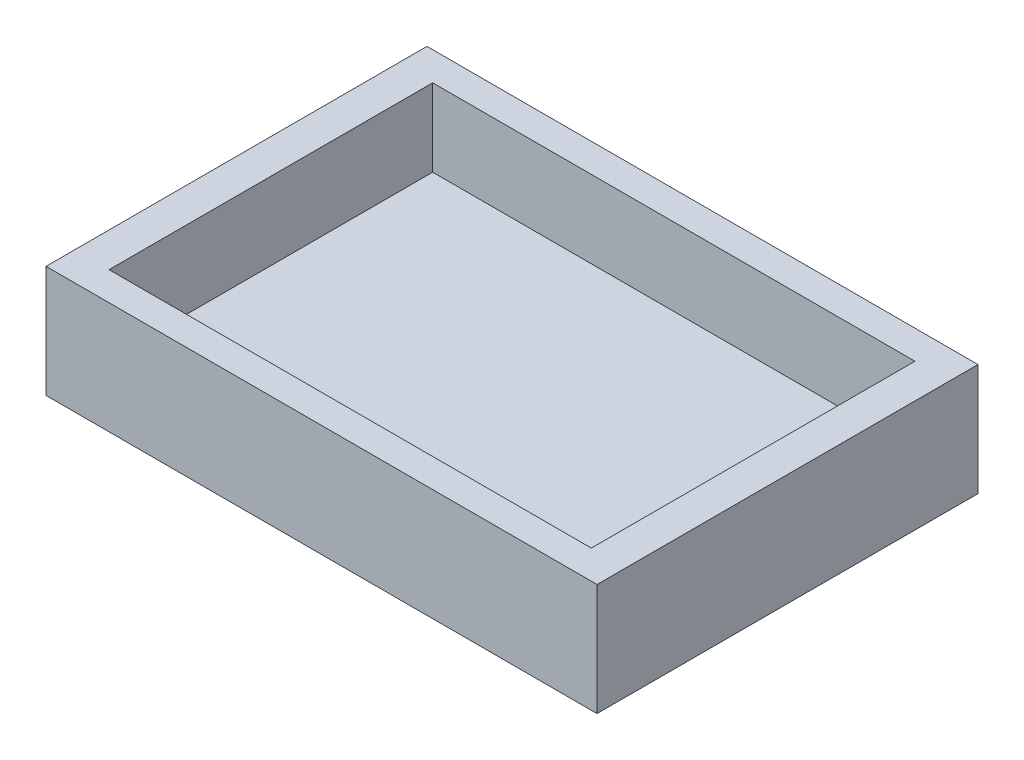
from build123d import *

# Parameters (mm, degrees)
SKETCH1_W           = 97.6
SKETCH1_H           = 66.43745389
BOSS_EXTRUDE1_DEPTH = 6
SKETCH4_W           = 24.6
SKETCH4_H           = 54
SKETCH4_H_2         = 6.218726945
SKETCH4_W_2         = 55
SKETCH4_W_3         = 18
BOSS_EXTRUDE2_DEPTH = 13.5
SKETCH6_W           = 97.6
SKETCH6_H           = 56.43745389
CUT_EXTRUDE2_DEPTH  = 13.5
SKETCH7_W           = 66.43745389
SKETCH7_H           = 19.5
CUT_EXTRUDE3_DEPTH  = 0.75
SKETCH8_W           = 66.43745389
SKETCH8_H           = 19.5
CUT_EXTRUDE4_DEPTH  = 0.75
SKETCH9_W           = 6
SKETCH9_H           = 56.43745389
BOSS_EXTRUDE3_DEPTH = 13.5


with BuildPart() as part:
    # Sketch1 → Boss-Extrude1 (new body)
    with BuildSketch(Plane(origin=(0, 0, 0), x_dir=(1, 0, 0), z_dir=(0, 1, 0))):
        Rectangle(SKETCH1_W, SKETCH1_H)
    extrude(amount=BOSS_EXTRUDE1_DEPTH)

    # Sketch4 → Boss-Extrude2 (add)
    with BuildSketch(Plane(origin=(0, 6, 0), x_dir=(1, 0, 0), z_dir=(0, 1, 0))):
        with Locations((-36.5, 0)):
            Rectangle(SKETCH4_W, SKETCH4_H)
        with Locations((-36.5, -30.109363473)):
            Rectangle(SKETCH4_W, SKETCH4_H_2)
        with Locations((3.3, -30.109363473)):
            Rectangle(SKETCH4_W_2, SKETCH4_H_2)
        with Locations((39.8, -30.109363473)):
            Rectangle(SKETCH4_W_3, SKETCH4_H_2)
        with Locations((39.8, 0)):
            Rectangle(SKETCH4_W_3, SKETCH4_H)
        with Locations((39.8, 30.109363473)):
            Rectangle(SKETCH4_W_3, SKETCH4_H_2)
        with Locations((-36.5, 30.109363473)):
            Rectangle(SKETCH4_W, SKETCH4_H_2)
        with Locations((3.3, 30.109363473)):
            Rectangle(SKETCH4_W_2, SKETCH4_H_2)
    extrude(amount=BOSS_EXTRUDE2_DEPTH)

    # Sketch6 → Cut-Extrude2 (cut)
    with BuildSketch(Plane(origin=(0, 19.5, 0), x_dir=(1, 0, 0), z_dir=(0, 1, 0))):
        Rectangle(SKETCH6_W, SKETCH6_H)
    extrude(amount=-CUT_EXTRUDE2_DEPTH, mode=Mode.SUBTRACT)

    # Sketch7 → Cut-Extrude3 (cut)
    with BuildSketch(Plane(origin=(48.8, 0, 0), x_dir=(0, 0, -1), z_dir=(1, 0, 0))):
        with Locations((0, 9.75)):
            Rectangle(SKETCH7_W, SKETCH7_H)
    extrude(amount=-CUT_EXTRUDE3_DEPTH, mode=Mode.SUBTRACT)

    # Sketch8 → Cut-Extrude4 (cut)
    with BuildSketch(Plane.ZY.offset(48.8)):
        with Locations((0, 9.75)):
            Rectangle(SKETCH8_W, SKETCH8_H)
    extrude(amount=-CUT_EXTRUDE4_DEPTH, mode=Mode.SUBTRACT)

    # Sketch9 → Boss-Extrude3 (add)
    with BuildSketch(Plane(origin=(0, 6, 0), x_dir=(1, 0, 0), z_dir=(0, 1, 0))):
        with Locations((-45.05, 0)):
            Rectangle(SKETCH9_W, SKETCH9_H)
        with Locations((45.05, 0)):
            Rectangle(SKETCH9_W, SKETCH9_H)
    extrude(amount=BOSS_EXTRUDE3_DEPTH)


solid = part.part
